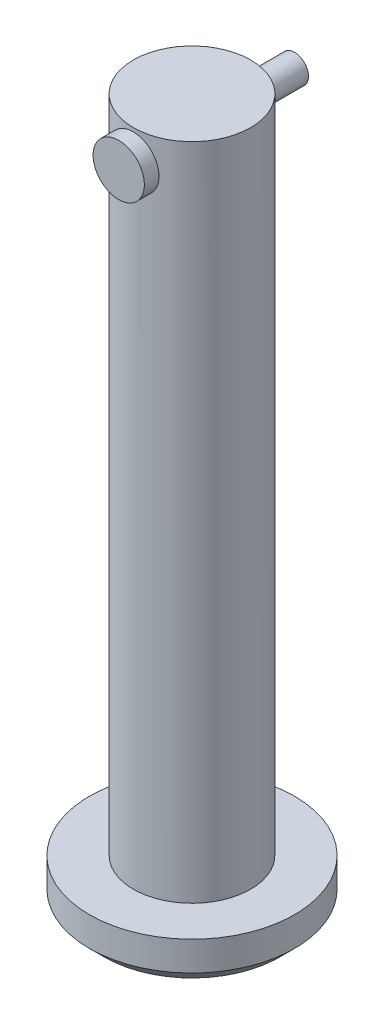
from build123d import *

# Parameters (mm, degrees)
SKETCH1_R                = 4
BOSS_EXTRUDE1_DEPTH      = 45
SKETCH2_R                = 7
BOSS_EXTRUDE2_DEPTH      = 3
CHAMFER1_SIZE            = 1
SKETCH3_R                = 1
CUT_EXTRUDE1_DEPTH       = 10
CUT_EXTRUDE1_DEPTH_BACK  = 10
SKETCH4_R                = 0.95
BOSS_EXTRUDE3_DEPTH      = 5
BOSS_EXTRUDE3_DEPTH_BACK = 7
SKETCH5_R                = 1.75
BOSS_EXTRUDE4_DEPTH      = 1


with BuildPart() as part:
    # Sketch1 → Boss-Extrude1 (new body)
    with BuildSketch(Plane(origin=(0, 0, 0), x_dir=(1, 0, 0), z_dir=(0, 1, 0))):
        Circle(SKETCH1_R)
    extrude(amount=BOSS_EXTRUDE1_DEPTH)

    # Sketch2 → Boss-Extrude2 (add)
    with BuildSketch(Plane.XZ):
        Circle(SKETCH2_R)
    extrude(amount=BOSS_EXTRUDE2_DEPTH)

    # Chamfer1
    chamfer1_edges = [part.edges().sort_by_distance(p)[0] for p in [
        (-7, -3, 0),
    ]]
    chamfer(chamfer1_edges, length=CHAMFER1_SIZE)

    # Sketch3 → Cut-Extrude1 (cut, two sides)
    with BuildSketch(Plane.XY) as cut_extrude1_sk:
        with Locations((0, 43)):
            Circle(SKETCH3_R)
    extrude(amount=CUT_EXTRUDE1_DEPTH, mode=Mode.SUBTRACT)
    extrude(cut_extrude1_sk.sketch, amount=-CUT_EXTRUDE1_DEPTH_BACK, mode=Mode.SUBTRACT)


with BuildPart() as body_2:
    # Sketch4 → Boss-Extrude3 (new body, two sides)
    with BuildSketch(Plane.XY) as boss_extrude3_sk:
        with Locations((0, 43)):
            Circle(SKETCH4_R)
    extrude(amount=BOSS_EXTRUDE3_DEPTH)
    extrude(boss_extrude3_sk.sketch, amount=-BOSS_EXTRUDE3_DEPTH_BACK)

    # Sketch5 → Boss-Extrude4 (add)
    with BuildSketch(Plane.XY.offset(5)):
        with Locations((0, 43)):
            Circle(SKETCH5_R)
    extrude(amount=-BOSS_EXTRUDE4_DEPTH)


solid = Compound([part.part, body_2.part])
